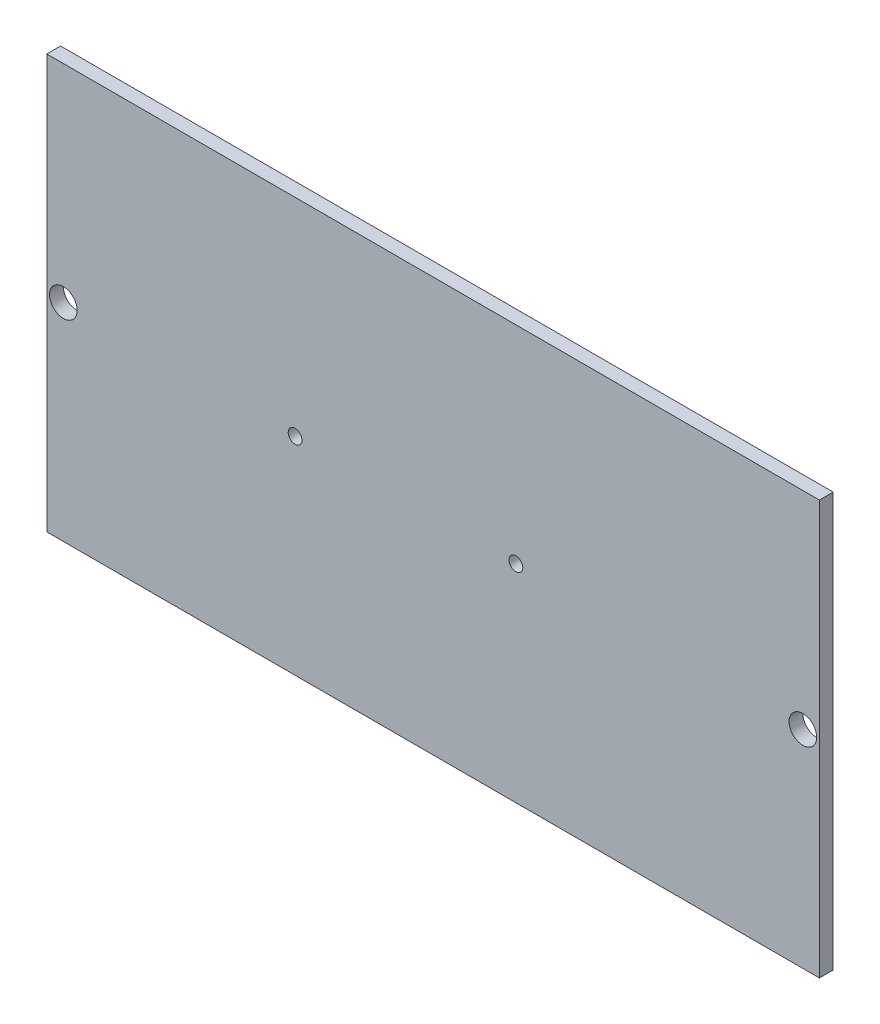
from build123d import *

# Parameters (mm, degrees)
ESQUISSE1_W             = 280
ESQUISSE1_H             = 150
BOSS_EXTRU_1_DEPTH      = 5
ESQUISSE2_R             = 2.5
ENL_V_MAT_EXTRU_1_DEPTH = 5
ESQUISSE3_R             = 5
ENL_V_MAT_EXTRU_2_DEPTH = 6


with BuildPart() as part:
    # Esquisse1 → Boss.-Extru.1 (new body)
    with BuildSketch(Plane.XY):
        with Locations((140, 75)):
            Rectangle(ESQUISSE1_W, ESQUISSE1_H)
    extrude(amount=BOSS_EXTRU_1_DEPTH)

    # Esquisse2 → Enlèv. mat.-Extru.1 (cut)
    with BuildSketch(Plane.XY.offset(5)):
        with Locations((90, 75)):
            Circle(ESQUISSE2_R)
        with Locations((170, 75)):
            Circle(ESQUISSE2_R)
    extrude(amount=-ENL_V_MAT_EXTRU_1_DEPTH, mode=Mode.SUBTRACT)

    # Esquisse3 → Enlèv. mat.-Extru.2 (cut, through all)
    with BuildSketch(Plane.XY.offset(5)):
        with Locations((6, 75)):
            Circle(ESQUISSE3_R)
    enl_v_mat_extru_2 = extrude(amount=-ENL_V_MAT_EXTRU_2_DEPTH, mode=Mode.SUBTRACT)

    # Symétrie1: Enlèv. mat.-Extru.2 across plane
    add(enl_v_mat_extru_2.mirror(Plane.ZY.offset(-140)), mode=Mode.SUBTRACT)


solid = part.part
